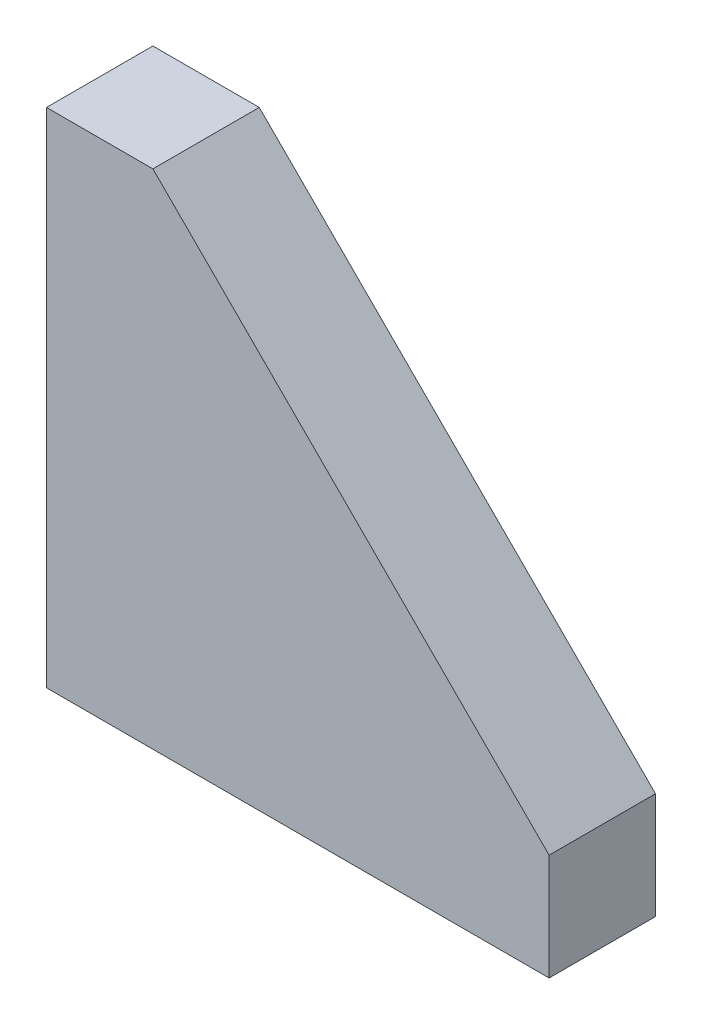
from build123d import *

# Parameters (mm, degrees)
BOSS_EXTRUDE1_DEPTH = 6.35


with BuildPart() as part:
    # Sketch1 → Boss-Extrude1 (new body)
    with BuildSketch(Plane.XY):
        Polygon((0, 0), (0, 30), (6.35, 30), (30, 6.35), (30, 0), align=None)
    extrude(amount=BOSS_EXTRUDE1_DEPTH)


solid = part.part
